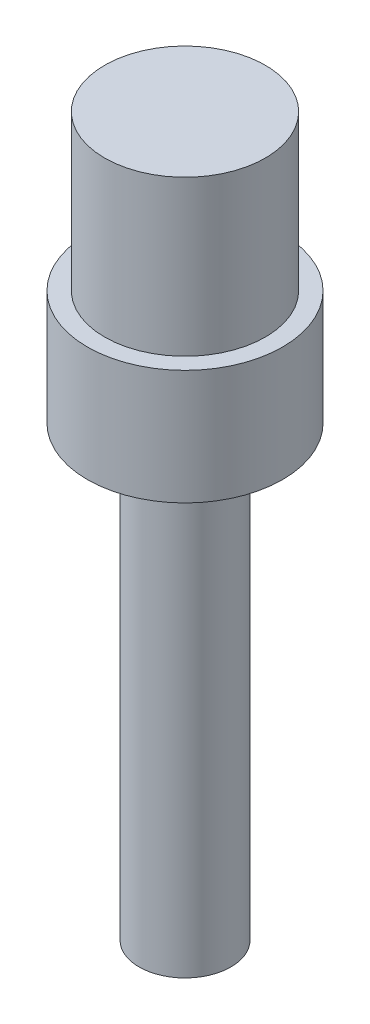
from build123d import *

# Parameters (mm, degrees)
ESBO_O1_R                = 8.5
RESSALTO_EXTRUS_O1_DEPTH = 10
ESBO_O2_R                = 7
RESSALTO_EXTRUS_O2_DEPTH = 13.5
ESBO_O3_R                = 4
RESSALTO_EXTRUS_O3_DEPTH = 39


with BuildPart() as part:
    # Esboço1 → Ressalto-extrusão1 (new body)
    with BuildSketch(Plane(origin=(0, 0, 0), x_dir=(1, 0, 0), z_dir=(0, 1, 0))):
        Circle(ESBO_O1_R)
    extrude(amount=RESSALTO_EXTRUS_O1_DEPTH)

    # Esboço2 → Ressalto-extrusão2 (add)
    with BuildSketch(Plane(origin=(0, 10, 0), x_dir=(1, 0, 0), z_dir=(0, 1, 0))):
        Circle(ESBO_O2_R)
    extrude(amount=RESSALTO_EXTRUS_O2_DEPTH)

    # Esboço3 → Ressalto-extrusão3 (add)
    with BuildSketch(Plane.XZ):
        Circle(ESBO_O3_R)
    extrude(amount=RESSALTO_EXTRUS_O3_DEPTH)


solid = part.part
